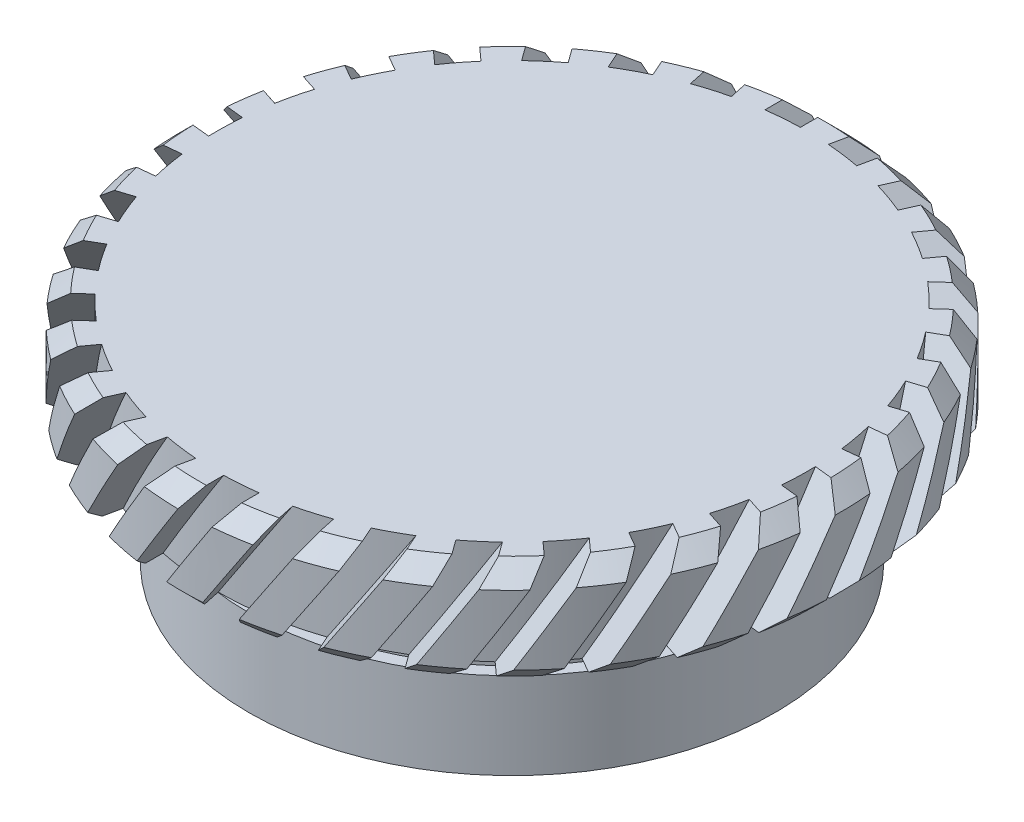
from build123d import *

# Parameters (mm, degrees)
CHAMFER_1_SIZE           = 0.5
CUT_EXTRUDE_1_REACH      = 57.687
CUT_EXTRUDE_1_END_RADIUS = 8.525
CUT_EXTRUDE_START        = 30
PATTERN_CIRCULAR_2_COUNT = 30


with BuildPart() as part:
    # 草图1 → 旋转2 (revolve)
    with BuildSketch(Plane.XY, mode=Mode.PRIVATE) as revolve_2_sk:
        Polygon((0, 21.871257405), (9.525, 21.871257405), (9.525, 18.871257405), (7.25, 18.871257405), (7.25, 17.871257405), (7.6, 17.871257405), (7.6, 15.371257405), (6.25, 15.371257405), (6.25, 18.871257405), (0, 18.871257405), align=None)
    revolve(revolve_2_sk.sketch.rotate(Axis((0, 66.628762136, 0), (0, -1, 0)), 90), axis=Axis((0, 66.628762136, 0), (0, -1, 0)))

    # 倒角1
    chamfer_1_edges = [part.edges().sort_by_distance(p)[0] for p in [
        (0, 21.871257405, -9.525),
        (0, 18.871257405, -9.525),
    ]]
    chamfer(chamfer_1_edges, length=CHAMFER_1_SIZE)

    # 切除-拉伸1: up to this cylinder (the profile starts outside it)
    cut_extrude_1_end = Plane(origin=(0, 18.072086, 0), z_dir=(0, 1, 0)) * Cylinder(CUT_EXTRUDE_1_END_RADIUS, 133.424, mode=Mode.PRIVATE)
    # 草图2 → 切除-拉伸1 (cut, up to the surface)
    with BuildSketch(Plane.XY.offset(CUT_EXTRUDE_START), mode=Mode.PRIVATE) as cut_extrude_1_sk1:
        Polygon((1.108168834, 23.303253722), (-5.339513804, 13.273525174), (-4.666571024, 12.840919101), (1.781111614, 22.870647649), align=None)
    cut_extrude_1_tool1 = extrude(cut_extrude_1_sk1.sketch, amount=-CUT_EXTRUDE_1_REACH, mode=Mode.PRIVATE) - cut_extrude_1_end
    cut_extrude_1 = cut_extrude_1_tool1.solids().sort_by_distance((-1.779201, 18.072086, 30))[0]
    add(cut_extrude_1, mode=Mode.SUBTRACT)

    # 阵列(圆周)2: 切除-拉伸1 ×30 about axis
    pattern_circular_2_axis = Axis((0, 0, 0), (0, 1, 0))
    for i in range(1, PATTERN_CIRCULAR_2_COUNT):
        add(cut_extrude_1.rotate(pattern_circular_2_axis, i * 360 / PATTERN_CIRCULAR_2_COUNT), mode=Mode.SUBTRACT)


solid = part.part
